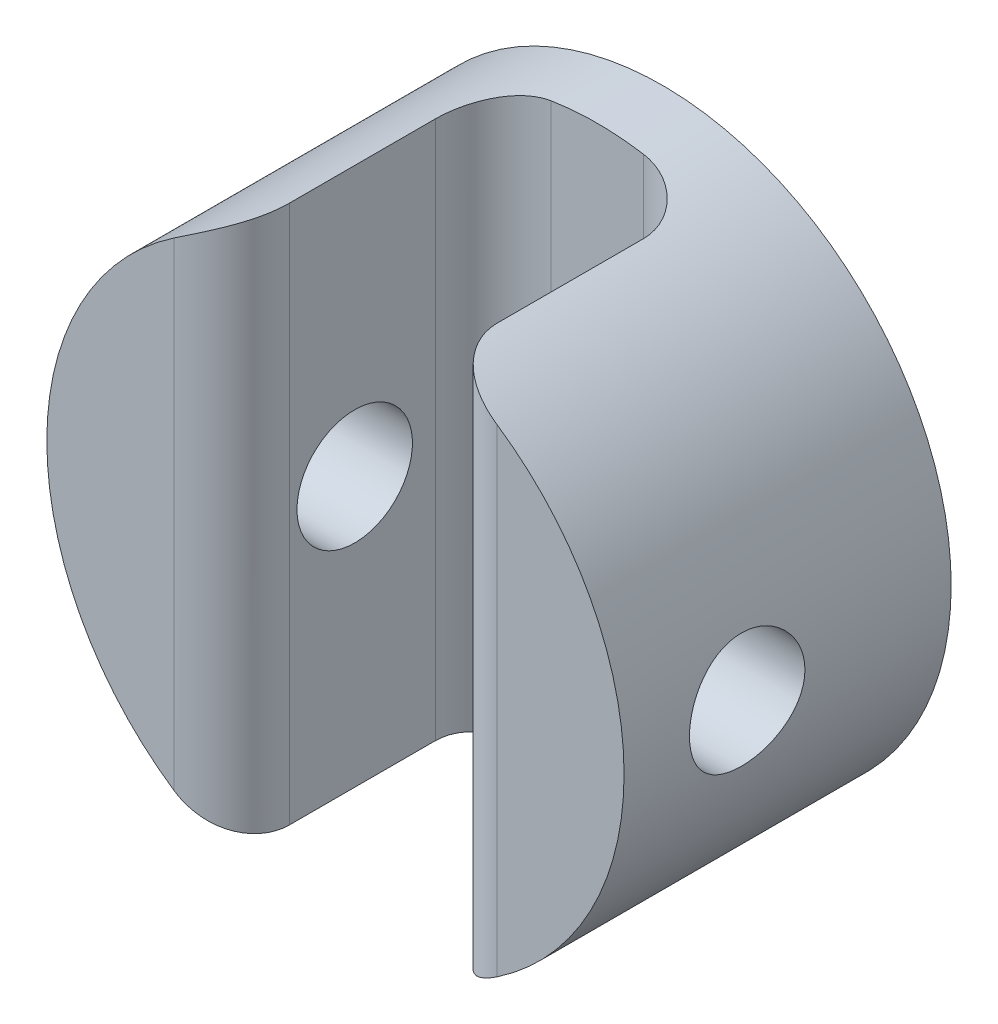
from build123d import *

# Parameters (mm, degrees)
SKETCH1_R               = 7.5
BOSS_EXTRUDE1_DEPTH     = 8.5
CUT_EXTRUDE1_DEPTH      = 6.8
SKETCH3_R               = 1.5
CUT_EXTRUDE2_DEPTH      = 11.2
CUT_EXTRUDE2_DEPTH_BACK = 5.8
FILLET1_R               = 1.5


with BuildPart() as part:
    # Sketch1 → Boss-Extrude1 (new body)
    with BuildSketch(Plane.XY):
        Circle(SKETCH1_R)
    extrude(amount=BOSS_EXTRUDE1_DEPTH)

    # Sketch2 → Cut-Extrude1 (cut)
    with BuildSketch(Plane.XY.offset(8.5)):
        Polygon((2.7, 0), (2.7, 13.78279584), (-2.7, 13.78279584), (-2.7, 0), (-2.7, -14.12853377), (2.7, -14.12853377), align=None)
    extrude(amount=-CUT_EXTRUDE1_DEPTH, mode=Mode.SUBTRACT)

    # Sketch3 → Cut-Extrude2 (cut, two sides)
    with BuildSketch(Plane(origin=(-2.7, 0, 0), x_dir=(0, 0, -1), z_dir=(1, 0, 0))) as cut_extrude2_sk:
        with Locations((-5.3, 0)):
            Circle(SKETCH3_R)
    extrude(amount=CUT_EXTRUDE2_DEPTH, mode=Mode.SUBTRACT)
    extrude(cut_extrude2_sk.sketch, amount=-CUT_EXTRUDE2_DEPTH_BACK, mode=Mode.SUBTRACT)

    # Fillet1
    fillet1_edges = [part.edges().sort_by_distance(p)[0] for p in [
        (-2.7, 0, 1.7),
        (2.7, 0, 1.7),
        (2.7, 0, 8.5),
        (-2.7, 0, 8.5),
    ]]
    fillet(fillet1_edges, radius=FILLET1_R)


solid = part.part
